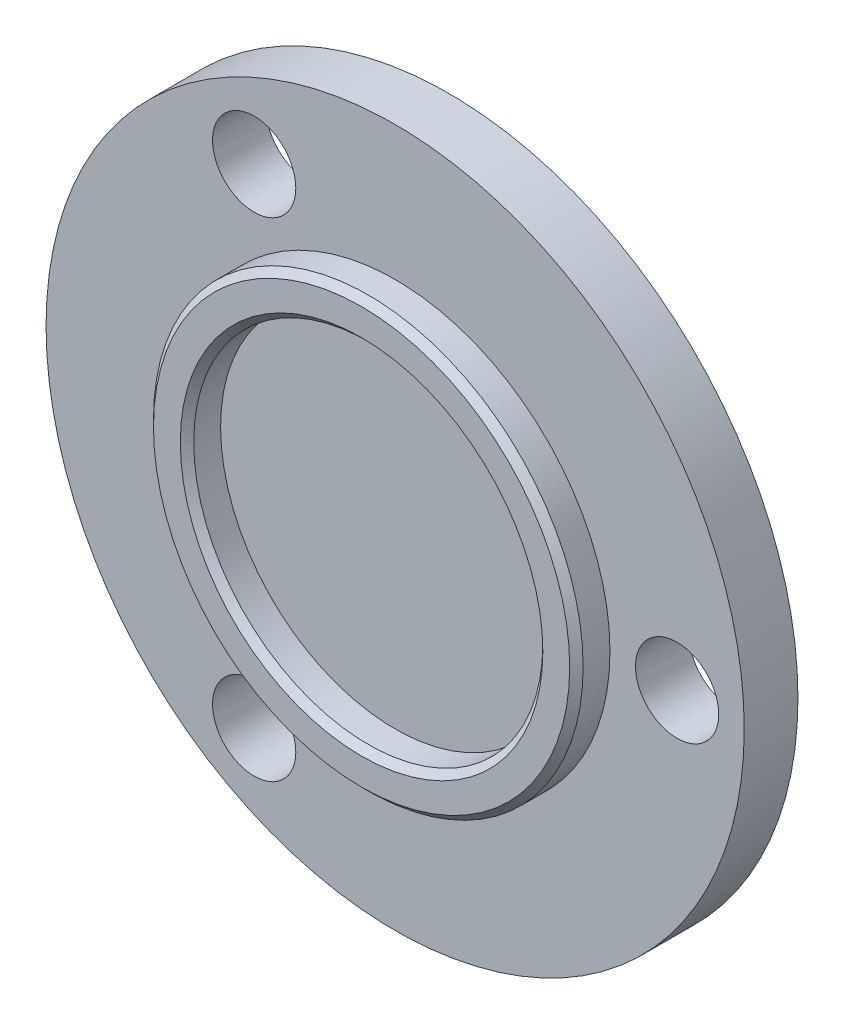
from build123d import *

# Parameters (mm, degrees)
SKETCH1_R           = 26
BOSS_EXTRUDE1_DEPTH = 4
SKETCH2_R           = 3.1
CUT_EXTRUDE1_DEPTH  = 4
SKETCH4_R           = 16
SKETCH4_R_2         = 13
BOSS_EXTRUDE2_DEPTH = 2.5
CHAMFER1_SIZE       = 0.5
CHAMFER2_SIZE       = 0.5


with BuildPart() as part:
    # Sketch1 → Boss-Extrude1 (new body)
    with BuildSketch(Plane.XY):
        Circle(SKETCH1_R)
    extrude(amount=BOSS_EXTRUDE1_DEPTH)

    # Sketch2 → Cut-Extrude1 (cut)
    with BuildSketch(Plane.XY.offset(4)):
        with Locations((21, 0)):
            Circle(SKETCH2_R)
        with Locations((-10.5, -18.186533479)):
            Circle(SKETCH2_R)
        with Locations((-10.5, 18.186533479)):
            Circle(SKETCH2_R)
    extrude(amount=-CUT_EXTRUDE1_DEPTH, mode=Mode.SUBTRACT)

    # Sketch4 → Boss-Extrude2 (add)
    with BuildSketch(Plane.XY.offset(4)):
        Circle(SKETCH4_R)
        Circle(SKETCH4_R_2, mode=Mode.SUBTRACT)
    extrude(amount=BOSS_EXTRUDE2_DEPTH)

    # Chamfer1
    chamfer1_edges = [part.edges().sort_by_distance(p)[0] for p in [
        (-16, 0, 6.5),
    ]]
    chamfer(chamfer1_edges, length=CHAMFER1_SIZE)

    # Chamfer2
    chamfer2_edges = [part.edges().sort_by_distance(p)[0] for p in [
        (-13, 0, 6.5),
    ]]
    chamfer(chamfer2_edges, length=CHAMFER2_SIZE)


solid = part.part
